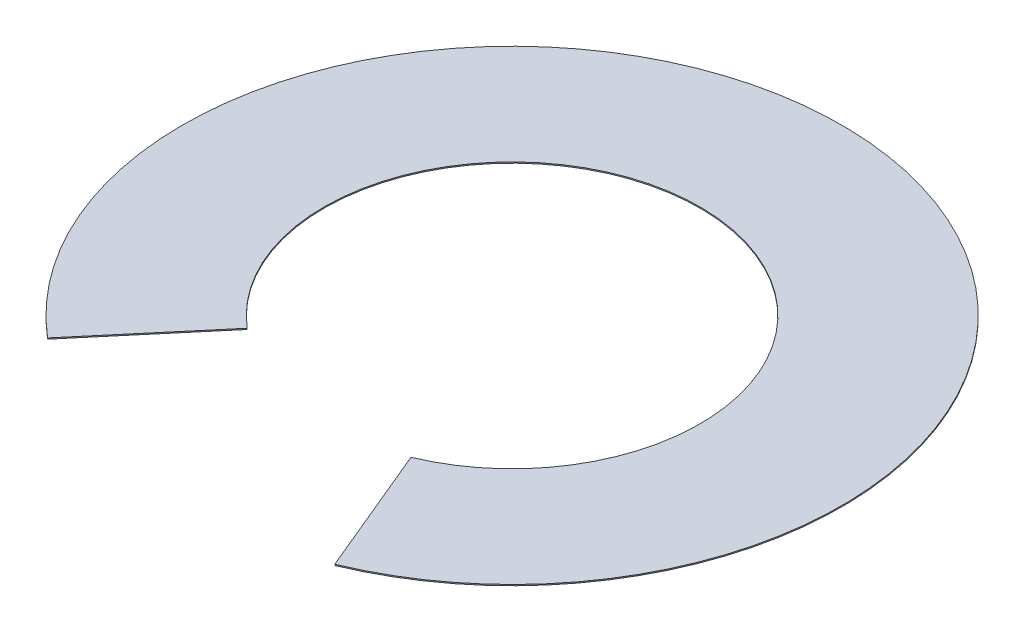
from build123d import *

# Parameters (mm, degrees)
BOSS_EXTRUDE1_DEPTH = 1.6


with BuildPart() as part:
    # Sketch1 → Boss-Extrude1 (new body)
    with BuildSketch(Plane(origin=(0, 0, 0), x_dir=(1, 0, 0), z_dir=(0, 1, 0))):
        with BuildLine():
            Line((-172.957520304, -204.718577981), (-303.321024413, -359.021386757))
            ThreePointArc((-303.321024413, -359.021386757), (71.701010727, 464.498616856), (180.943491032, -433.773504323))
            Line((180.943491032, -433.773504323), (103.176288503, -247.343189699))
            ThreePointArc((103.176288503, -247.343189699), (40.884831648, 264.863041101), (-172.957520304, -204.718577981))
        make_face()
    extrude(amount=BOSS_EXTRUDE1_DEPTH)


solid = part.part
